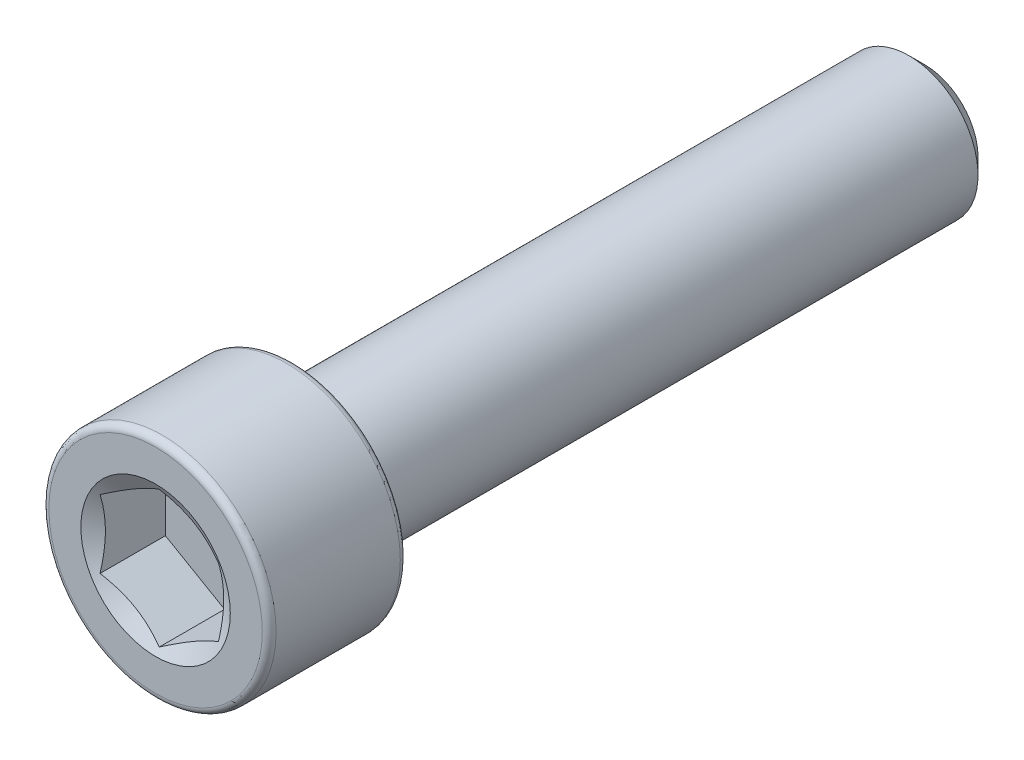
from build123d import *

# Parameters (mm, degrees)
CUT_EXTRUDE1_START = 11.6078
CUT_EXTRUDE1_DEPTH = 2.0828


with BuildPart() as part:
    # Sketch2 → Revolve1 (revolve)
    with BuildSketch(Plane(origin=(0, 0, 0), x_dir=(0, 0, -1), z_dir=(1, 0, 0)), mode=Mode.PRIVATE) as revolve1_sk:
        with BuildLine():
            Line((11.6078, 0), (11.6078, 1.60655))
            Line((11.6078, 1.60655), (11.13155, 2.0828))
            Line((11.13155, 2.0828), (-7.4422, 2.0828))
            Line((-7.4422, 2.0828), (-7.4422, 3.22072))
            ThreePointArc((-7.4422, 3.22072), (-7.5032038, 3.3679962), (-7.65048, 3.429))
            Line((-7.65048, 3.429), (-11.39952, 3.429))
            ThreePointArc((-11.39952, 3.429), (-11.5467962, 3.3679962), (-11.6078, 3.22072))
            Line((-11.6078, 3.22072), (-11.6078, 0))
            Line((-11.6078, 0), (11.6078, 0))
        make_face()
    revolve(revolve1_sk.sketch.rotate(Axis((0, 0, -11.6078), (0, 0, 1)), 90), axis=Axis((0, 0, -11.6078), (0, 0, 1)))

    # Sketch3 → Cut-Extrude1 (cut)
    with BuildSketch(Plane.XY.offset(CUT_EXTRUDE1_START)):
        Polygon((-1.7859375, 1.031111496), (-1.7859375, -1.031111496), (0, -2.062222993), (1.7859375, -1.031111496), (1.7859375, 1.031111496), (0, 2.062222993), align=None)
    extrude(amount=-CUT_EXTRUDE1_DEPTH, mode=Mode.SUBTRACT)

    # Cut-Extrude2 cone 1 section (through the dimple's axis) → Cut-Extrude2 (revolve, cut)
    with BuildSketch(Plane(origin=(0, 0, 11.6078), x_dir=(0, -1, 0), z_dir=(1, 0, 0))):
        Polygon((0, 0), (2.255305827, 0), (0, 1.302101426), align=None)
    revolve(axis=Axis((0, 0, 11.6078), (0, 0, -1)), mode=Mode.SUBTRACT)


solid = part.part
